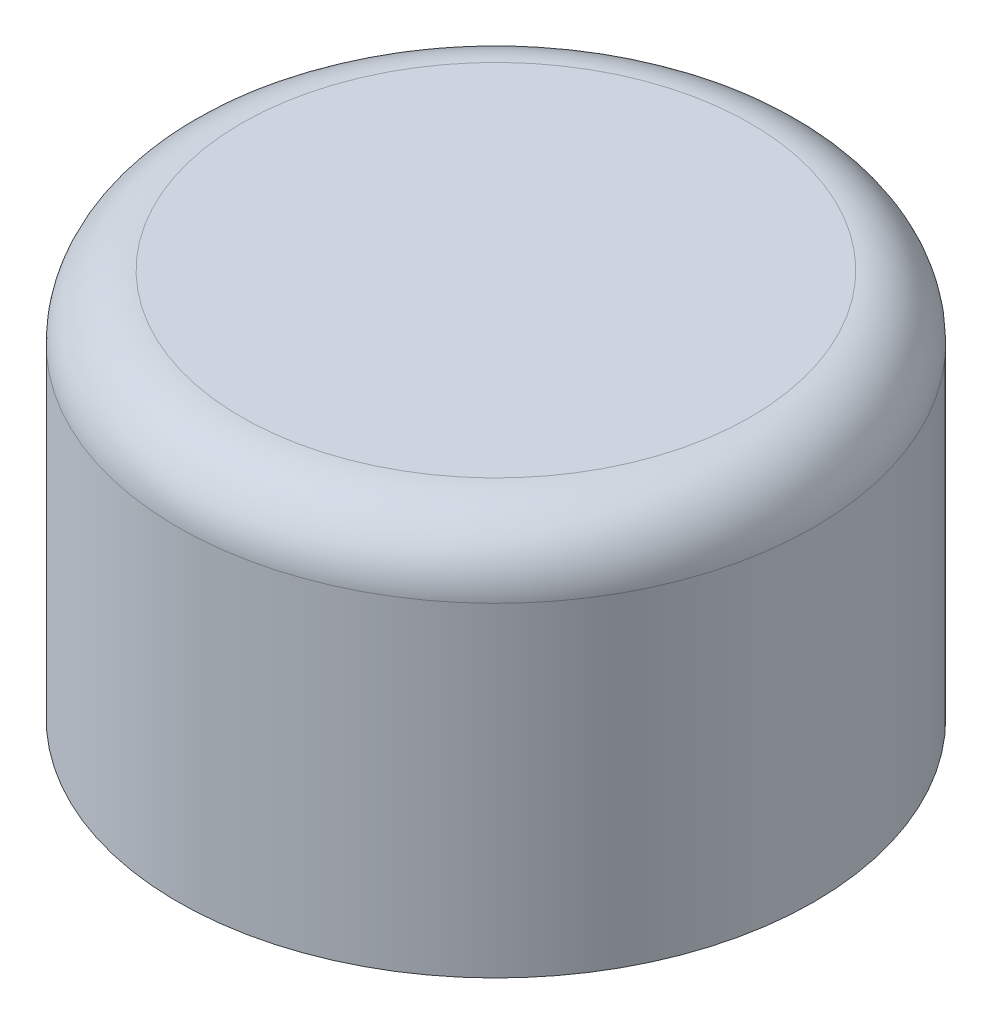
from build123d import *


with BuildPart() as part:
    # Sketch1 → Revolve1 (revolve)
    with BuildSketch(Plane.XY):
        with BuildLine():
            Line((0, 12.954), (-10.16, 12.954))
            Line((-10.16, 12.954), (-10.16, 0))
            Line((-10.16, 0), (-12.7, 0))
            Line((-12.7, 0), (-12.7, 12.954))
            ThreePointArc((-12.7, 12.954), (-11.956051224, 14.750051224), (-10.16, 15.494))
            Line((-10.16, 15.494), (0, 15.494))
            Line((0, 15.494), (0, 12.954))
        make_face()
    revolve(axis=Axis((0, 0, 0), (0, 1, 0)))


solid = part.part
